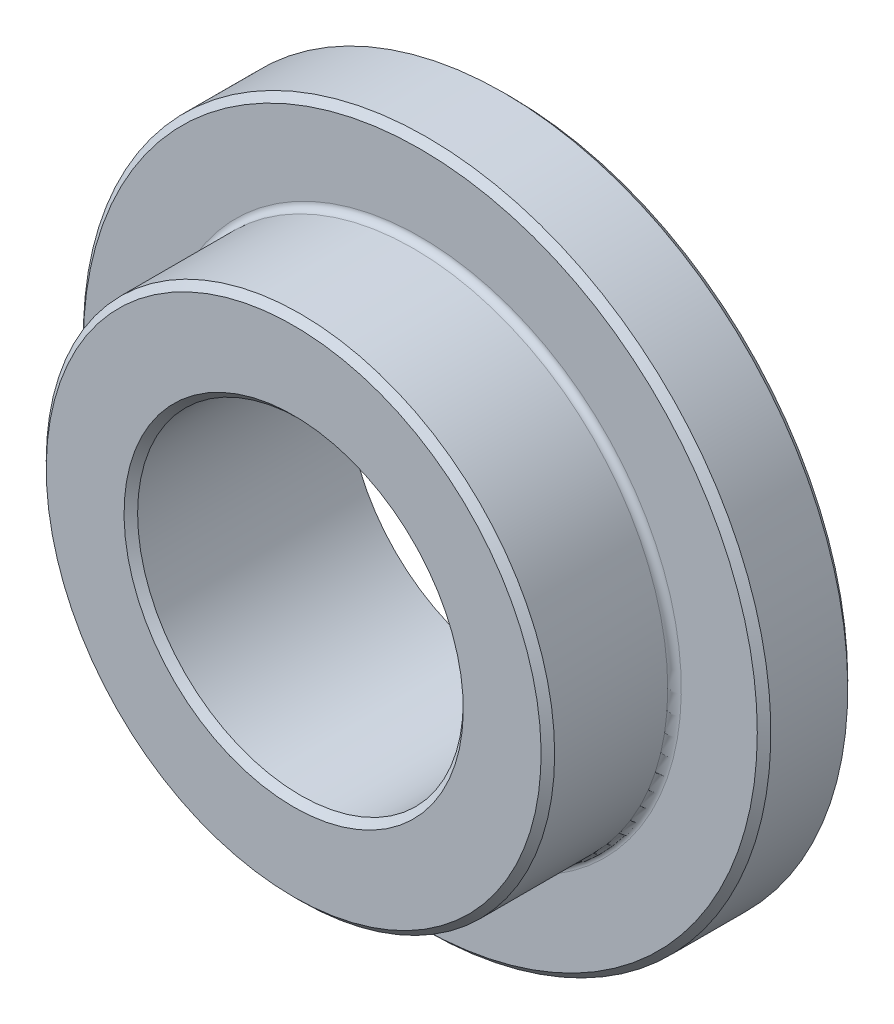
from build123d import *

# Parameters (mm, degrees)
CHAMFER1_SIZE = 0.1875
FILLET1_R     = 0.1875


with BuildPart() as part:
    # Sketch3 → Revolve1 (revolve)
    with BuildSketch(Plane(origin=(0, 0, 0), x_dir=(0, 0, -1), z_dir=(1, 0, 0))):
        Polygon((3, 9.5), (0.5, 9.5), (0.5, 7.025), (-3, 7.025), (-3, 4.5), (3, 4.5), align=None)
    revolve(axis=Axis((0, 0, -3), (0, 0, 1)))

    # Chamfer1
    chamfer1_edges = [part.edges().sort_by_distance(p)[0] for p in [
        (0, -4.5, 3),
        (0, -7.025, 3),
        (0, -9.5, -0.5),
        (0, -9.5, -3),
    ]]
    chamfer(chamfer1_edges, length=CHAMFER1_SIZE)

    # Fillet1
    fillet1_edges = [part.edges().sort_by_distance(p)[0] for p in [
        (0, -7.025, -0.5),
    ]]
    fillet(fillet1_edges, radius=FILLET1_R)


solid = part.part
